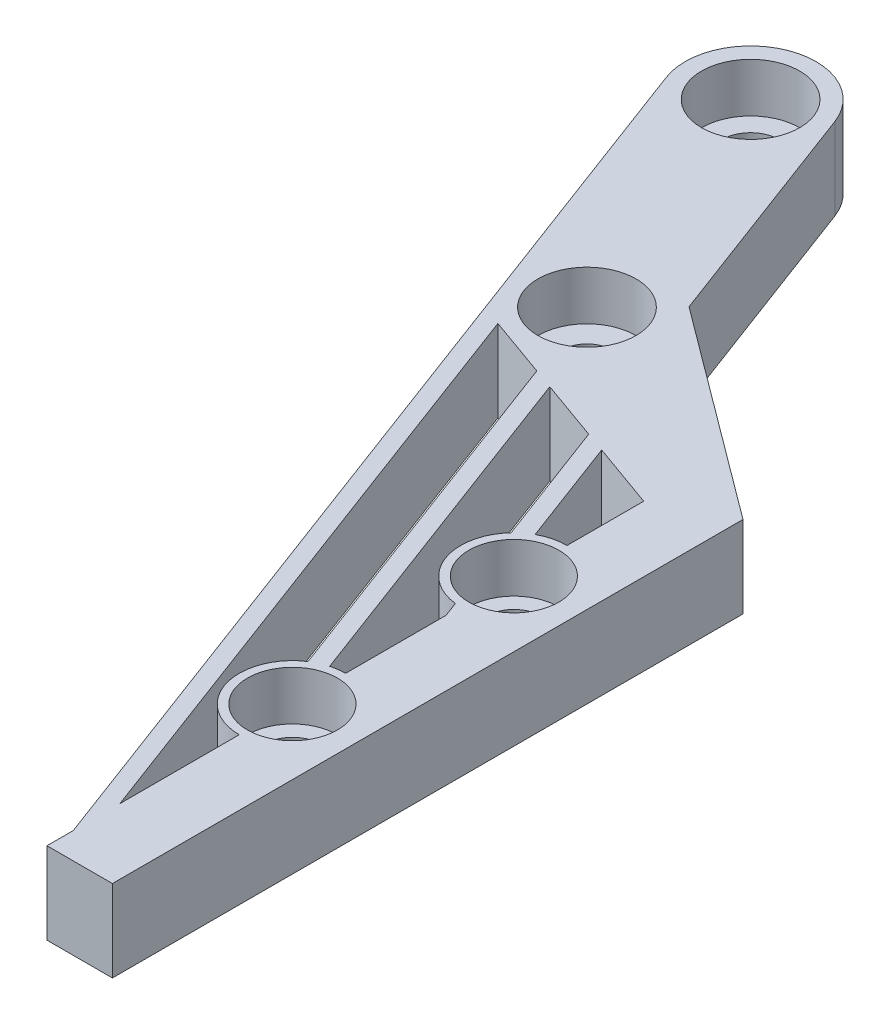
from build123d import *

# Parameters (mm, degrees)
SKIZZE1_R                       = 1.75
SKIZZE1_R_2                     = 1.5
AUFSATZ_LINEAR_AUSTRAGEN1_DEPTH = 5
AUFSATZ_LINEAR_AUSTRAGEN2_DEPTH = 5
SKIZZE4_R                       = 3.25
AUFSATZ_LINEAR_AUSTRAGEN3_DEPTH = 5
SKIZZE5_R                       = 1.75
SCHNITT_LINEAR_AUSTRAGEN2_DEPTH = 5
SKIZZE3_R                       = 3
SKIZZE3_R_2                     = 2.75
SCHNITT_LINEAR_AUSTRAGEN1_DEPTH = 3
SCHNITT_LINEAR_AUSTRAGEN3_DEPTH = 5


with BuildPart() as part:
    # Skizze1 → Aufsatz-Linear austragen1 (new body)
    with BuildSketch(Plane(origin=(0, 0, 0), x_dir=(1, 0, 0), z_dir=(0, 1, 0))):
        with BuildLine():
            Line((-3.74531671, -1.404493766), (2.906480569, -19.142619845))
            Line((2.906480569, -19.142619845), (18, -24.533162499))
            Line((18, -24.533162499), (18, -61))
            Line((18, -61), (22, -61))
            Line((22, -61), (22, -17.466837501))
            Line((22, -17.466837501), (9.093519431, -12.857380155))
            Line((9.093519431, -12.857380155), (3.74531671, 1.404493766))
            ThreePointArc((3.74531671, 1.404493766), (-1.404493766, 3.74531671), (-3.74531671, -1.404493766))
        make_face()
        Circle(SKIZZE1_R, mode=Mode.SUBTRACT)
        with Locations((6, -16)):
            Circle(SKIZZE1_R_2, mode=Mode.SUBTRACT)
    extrude(amount=AUFSATZ_LINEAR_AUSTRAGEN1_DEPTH)

    # Skizze2 → Aufsatz-Linear austragen2 (add)
    with BuildSketch(Plane(origin=(0, 5, 0), x_dir=(1, 0, 0), z_dir=(0, 1, 0))):
        Polygon((2.906480569, -19.142619845), (18, -59.392004994), (18, -56.544003745), (4.139635749, -19.58303241), align=None)
        Polygon((7.839101288, -20.904270102), (18, -48), (18, -45.151998752), (9.072256468, -21.344682666), align=None)
        Polygon((12.771722007, -22.665920359), (18, -36.607995006), (18, -33.759993758), (14.004877187, -23.106332923), align=None)
    extrude(amount=-AUFSATZ_LINEAR_AUSTRAGEN2_DEPTH)

    # Skizze4 → Aufsatz-Linear austragen3 (add)
    with BuildSketch(Plane(origin=(0, 5, 0), x_dir=(1, 0, 0), z_dir=(0, 1, 0))):
        with Locations((18, -32.466837501)):
            Circle(SKIZZE4_R)
        with Locations((18, -46)):
            Circle(SKIZZE4_R)
    extrude(amount=-AUFSATZ_LINEAR_AUSTRAGEN3_DEPTH)

    # Skizze5 → Schnitt-Linear austragen2 (cut)
    with BuildSketch(Plane(origin=(0, 5, 0), x_dir=(1, 0, 0), z_dir=(0, 1, 0))):
        with Locations((18, -32.466837501)):
            Circle(SKIZZE5_R)
        with Locations((18, -46)):
            Circle(SKIZZE5_R)
    extrude(amount=-SCHNITT_LINEAR_AUSTRAGEN2_DEPTH, mode=Mode.SUBTRACT)

    # Skizze3 → Schnitt-Linear austragen1 (cut)
    with BuildSketch(Plane(origin=(0, 5, 0), x_dir=(1, 0, 0), z_dir=(0, 1, 0))):
        Circle(SKIZZE3_R)
        with Locations((6, -16)):
            Circle(SKIZZE3_R)
        with Locations((18, -32.466837501)):
            Circle(SKIZZE3_R_2)
        with Locations((18, -46)):
            Circle(SKIZZE3_R_2)
    extrude(amount=-SCHNITT_LINEAR_AUSTRAGEN1_DEPTH, mode=Mode.SUBTRACT)

    # Skizze6 → Schnitt-Linear austragen3 (cut)
    with BuildSketch(Plane(origin=(0, 5, 0), x_dir=(1, 0, 0), z_dir=(0, 1, 0))):
        Polygon((9.093519431, -12.857380155), (22, -22.466837501), (22, -17.466837501), align=None)
    extrude(amount=-SCHNITT_LINEAR_AUSTRAGEN3_DEPTH, mode=Mode.SUBTRACT)


solid = part.part
